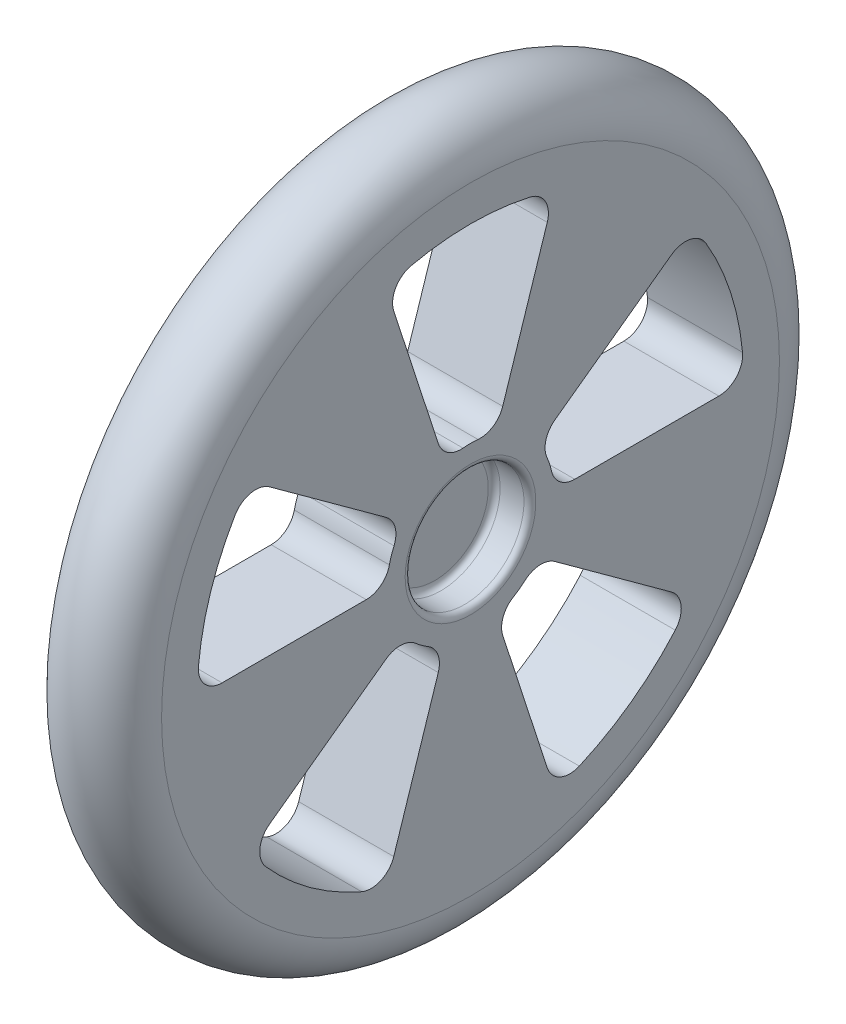
from build123d import *

# Parameters (mm, degrees)
CUT_EXTRUDE1_DEPTH = 8
CIRPATTERN1_COUNT  = 5


with BuildPart() as part:
    # Sketch3 → Revolve1 (revolve)
    with BuildSketch(Plane.XY):
        with BuildLine():
            Line((-1, 0), (1, 0))
            Line((1, 0), (1, 4.5))
            ThreePointArc((1, 4.5), (1.146446609, 4.853553391), (1.5, 5))
            Line((1.5, 5), (3.5, 5))
            ThreePointArc((3.5, 5), (3.853553391, 5.146446609), (4, 5.5))
            Line((4, 5.5), (4, 26))
            ThreePointArc((4, 26), (0, 30), (-4, 26))
            Line((-4, 26), (-4, 5.5))
            ThreePointArc((-4, 5.5), (-3.853553391, 5.146446609), (-3.5, 5))
            Line((-3.5, 5), (-1.5, 5))
            ThreePointArc((-1.5, 5), (-1.146446609, 4.853553391), (-1, 4.5))
            Line((-1, 4.5), (-1, 0))
        make_face()
    revolve(axis=Axis((0, 0, 0), (1, 0, 0)))

    # Sketch6 → Cut-Extrude1 (cut)
    with BuildSketch(Plane(origin=(4, 0, 0), x_dir=(0, 0, -1), z_dir=(1, 0, 0))):
        with BuildLine():
            Line((7.099095314, 5.157794656), (16.912132133, 12.287383234))
            ThreePointArc((16.912132133, 12.287383234), (18.494388462, 12.627564412), (19.810340984, 11.685477744))
            ThreePointArc((19.810340984, 11.685477744), (21.874299875, 7.107390871), (22.895454004, 2.19047619))
            ThreePointArc((22.895454004, 2.19047619), (22.3845707, 0.654814582), (20.90454496, 0))
            Line((20.90454496, 0), (8.774964387, 0))
            ThreePointArc((8.774964387, 0), (7.527745258, 0.43652808), (6.824972301, 1.555555556))
            ThreePointArc((6.824972301, 1.555555556), (6.657395614, 2.163118961), (6.435851193, 2.753147186))
            ThreePointArc((6.435851193, 2.753147186), (6.346658611, 4.071539011), (7.099095314, 5.157794656))
        make_face()
    cut_extrude1 = extrude(amount=-CUT_EXTRUDE1_DEPTH, mode=Mode.SUBTRACT)

    # CirPattern1: Cut-Extrude1 ×5 about axis
    cirpattern1_axis = Axis((0, 0, 0), (1, 0, 0))
    for i in range(1, CIRPATTERN1_COUNT):
        add(cut_extrude1.rotate(cirpattern1_axis, i * 360 / CIRPATTERN1_COUNT), mode=Mode.SUBTRACT)


solid = part.part
